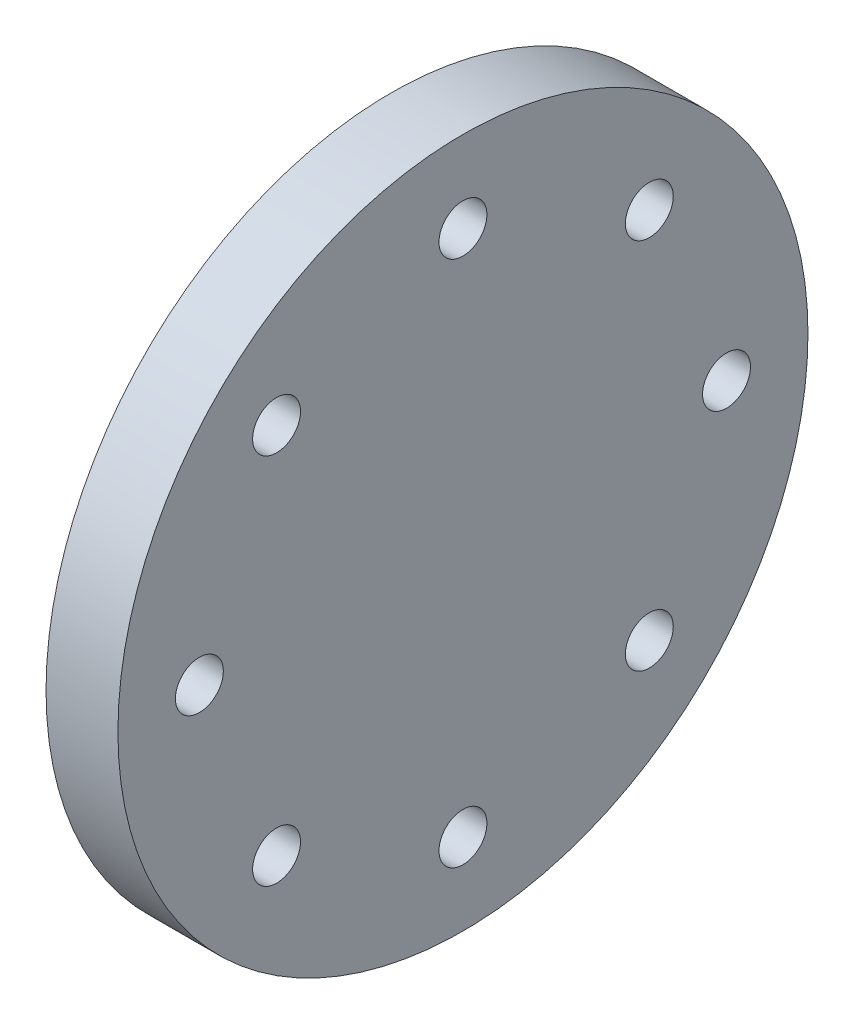
from build123d import *

# Parameters (mm, degrees)
SKETCH2_R           = 72
SKETCH2_R_2         = 5
BOSS_EXTRUDE1_DEPTH = 15


with BuildPart() as part:
    # Sketch2 → Boss-Extrude1 (new body)
    with BuildSketch(Plane(origin=(0, 0, 0), x_dir=(0, 0, -1), z_dir=(1, 0, 0))):
        Circle(SKETCH2_R)
        with Locations((0, 55)):
            Circle(SKETCH2_R_2, mode=Mode.SUBTRACT)
        with Locations((38.890872965, 38.890872965)):
            Circle(SKETCH2_R_2, mode=Mode.SUBTRACT)
        with Locations((55, 0)):
            Circle(SKETCH2_R_2, mode=Mode.SUBTRACT)
        with Locations((38.890872965, -38.890872965)):
            Circle(SKETCH2_R_2, mode=Mode.SUBTRACT)
        with Locations((0, -55)):
            Circle(SKETCH2_R_2, mode=Mode.SUBTRACT)
        with Locations((-38.890872965, -38.890872965)):
            Circle(SKETCH2_R_2, mode=Mode.SUBTRACT)
        with Locations((-55, 0)):
            Circle(SKETCH2_R_2, mode=Mode.SUBTRACT)
        with Locations((-38.890872965, 38.890872965)):
            Circle(SKETCH2_R_2, mode=Mode.SUBTRACT)
    extrude(amount=BOSS_EXTRUDE1_DEPTH)


solid = part.part
